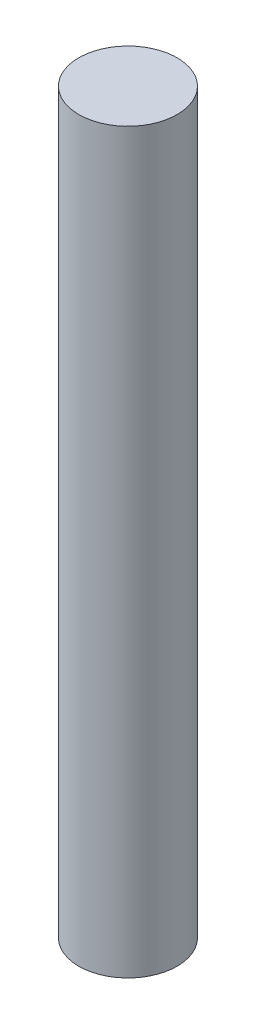
from build123d import *

# Parameters (mm, degrees)
SKETCH1_R           = 10
BOSS_EXTRUDE1_DEPTH = 150


with BuildPart() as part:
    # Sketch1 → Boss-Extrude1 (new body)
    with BuildSketch(Plane(origin=(0, 0, 0), x_dir=(1, 0, 0), z_dir=(0, 1, 0))):
        Circle(SKETCH1_R)
    extrude(amount=BOSS_EXTRUDE1_DEPTH)


solid = part.part
